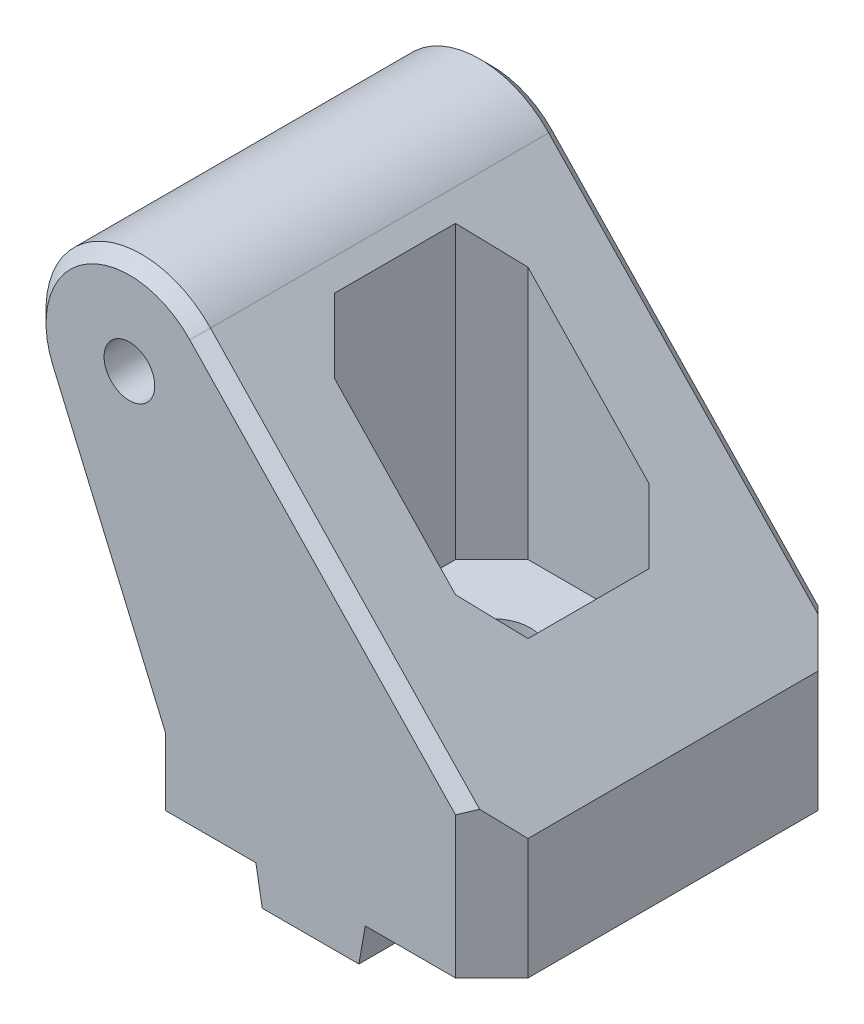
from build123d import *

# Parameters (mm, degrees)
CROQUIS1_R              = 2.1
SALIENTE_EXTRUIR1_DEPTH = 15
CHAFL_N1_SIZE           = 3
CORTAR_EXTRUIR1_START   = -10
CROQUIS3_W              = 16
CROQUIS3_H              = 16
CORTAR_EXTRUIR1_DEPTH   = 28.9
CHAFL_N2_SIZE           = 3
CROQUIS4_R              = 3.2
CORTAR_EXTRUIR2_DEPTH   = 14
CROQUIS5_W              = 10
CROQUIS5_H              = 10
CORTAR_EXTRUIR3_DEPTH   = 4
CHAFL_N3_SIZE           = 2.5
CHAFL_N4_SIZE           = 1


with BuildPart() as part:
    # Croquis1 → Saliente-Extruir1 (new body, symmetric)
    with BuildSketch(Plane.XY):
        with BuildLine():
            Line((-30, 0), (-30, 10))
            Line((-30, 10), (-37.257580847, 26.8795))
            ThreePointArc((-37.257580847, 26.8795), (-34.35566426, 36.590765423), (-24.284119395, 35.453320907))
            Line((-24.284119395, 35.453320907), (0, 10))
            Line((0, 10), (0, 0))
            Line((0, 0), (-10.471019058, 0))
            Line((-10.471019058, 0), (-11, -3))
            Line((-11, -3), (-19, -3))
            Line((-19, -3), (-19.528980942, 0))
            Line((-19.528980942, 0), (-30, 0))
        make_face()
        with Locations((-30, 30)):
            Circle(CROQUIS1_R, mode=Mode.SUBTRACT)
    extrude(amount=SALIENTE_EXTRUIR1_DEPTH, both=True)

    # Chaflán1
    chafl_n1_edges = [part.edges().sort_by_distance(p)[0] for p in [
        (-30, 5, -15),
        (0, 5, -15),
        (-30, 5, 15),
        (0, 5, 15),
    ]]
    chamfer(chafl_n1_edges, length=CHAFL_N1_SIZE)

    # Croquis3 → Cortar-Extruir1 (cut, through all)
    with BuildSketch(Plane.XZ.offset(CORTAR_EXTRUIR1_START)):
        with Locations((-15, 0)):
            Rectangle(CROQUIS3_W, CROQUIS3_H)
    extrude(amount=-CORTAR_EXTRUIR1_DEPTH, mode=Mode.SUBTRACT)

    # Chaflán2
    chafl_n2_edges = [part.edges().sort_by_distance(p)[0] for p in [
        (-23, 22.053687666, -8),
        (-23, 22.053687666, 8),
        (-7, 13.668513637, 8),
        (-7, 13.668513637, -8),
    ]]
    chamfer(chafl_n2_edges, length=CHAFL_N2_SIZE)

    # Croquis4 → Cortar-Extruir2 (cut, through all)
    with BuildSketch(Plane(origin=(0, 10, 0), x_dir=(1, 0, 0), z_dir=(0, 1, 0))):
        with Locations((-15, 0)):
            Circle(CROQUIS4_R)
    extrude(amount=-CORTAR_EXTRUIR2_DEPTH, mode=Mode.SUBTRACT)

    # Croquis5 → Cortar-Extruir3 (cut, through all)
    with BuildSketch(Plane.XZ):
        with Locations((-15, 0)):
            Rectangle(CROQUIS5_W, CROQUIS5_H)
    extrude(amount=CORTAR_EXTRUIR3_DEPTH, mode=Mode.SUBTRACT)

    # Chaflán3
    chafl_n3_edges = [part.edges().sort_by_distance(p)[0] for p in [
        (-15, -3, -5),
        (-15, -3, 5),
    ]]
    chamfer(chafl_n3_edges, length=CHAFL_N3_SIZE)

    # Chaflán4
    chafl_n4_edges = [part.edges().sort_by_distance(p)[0] for p in [
        (-32.128790423, 14.951087519, -15),
        (-34.35566426, 36.590765423, -15),
        (-34.35566426, 36.590765423, 15),
        (-32.128790423, 14.951087519, 15),
        (-13.642059698, 24.298880584, -15),
        (-13.642059698, 24.298880584, 15),
    ]]
    chamfer(chafl_n4_edges, length=CHAFL_N4_SIZE)


solid = part.part
